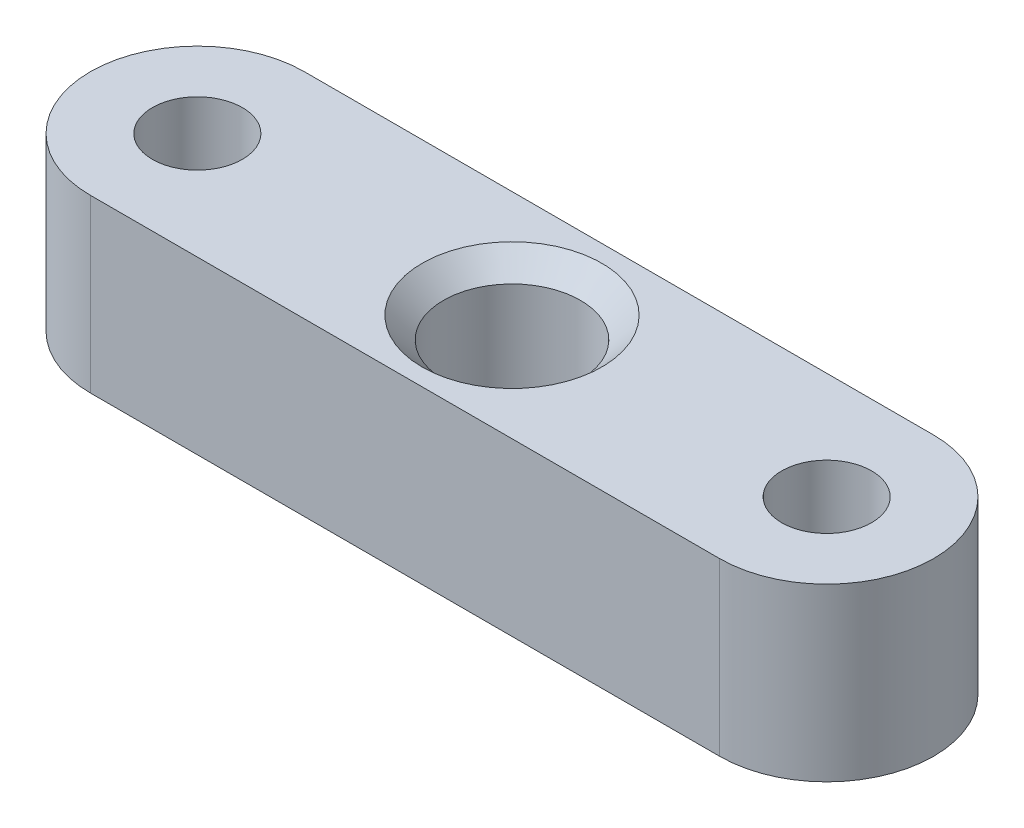
from build123d import *

# Parameters (mm, degrees)
SKETCH1_R           = 2.1
BOSS_EXTRUDE1_DEPTH = 8
SKETCH2_R           = 3.2
CUT_EXTRUDE1_DEPTH  = 6
SKETCH3_R           = 2
CUT_EXTRUDE2_DEPTH  = 6
CHAMFER1_SIZE       = 1


with BuildPart() as part:
    # Sketch1 → Boss-Extrude1 (new body)
    with BuildSketch(Plane(origin=(0, 0, 0), x_dir=(1, 0, 0), z_dir=(0, 1, 0))):
        with BuildLine():
            Line((-14.7, 5), (14.7, 5))
            ThreePointArc((14.7, 5), (19.7, 0), (14.7, -5))
            Line((14.7, -5), (-14.7, -5))
            ThreePointArc((-14.7, -5), (-19.7, 0), (-14.7, 5))
        make_face()
        with Locations((-14.7, 0)):
            Circle(SKETCH1_R, mode=Mode.SUBTRACT)
        with Locations((14.7, 0)):
            Circle(SKETCH1_R, mode=Mode.SUBTRACT)
    extrude(amount=BOSS_EXTRUDE1_DEPTH)

    # Sketch2 → Cut-Extrude1 (cut)
    with BuildSketch(Plane(origin=(0, 8, 0), x_dir=(1, 0, 0), z_dir=(0, 1, 0))):
        Circle(SKETCH2_R)
    extrude(amount=-CUT_EXTRUDE1_DEPTH, mode=Mode.SUBTRACT)

    # Sketch3 → Cut-Extrude2 (cut)
    with BuildSketch(Plane.XZ):
        Circle(SKETCH3_R)
    extrude(amount=-CUT_EXTRUDE2_DEPTH, mode=Mode.SUBTRACT)

    # Chamfer1
    chamfer1_edges = [part.edges().sort_by_distance(p)[0] for p in [
        (-3.2, 8, 0),
    ]]
    chamfer(chamfer1_edges, length=CHAMFER1_SIZE)


solid = part.part
